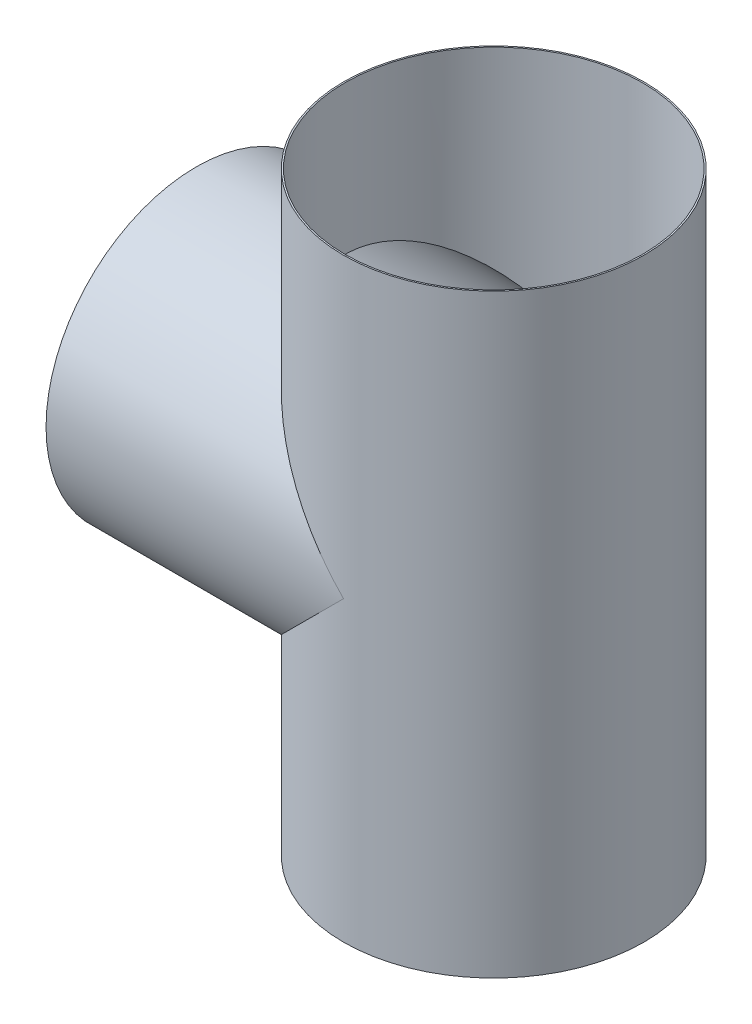
from build123d import *

# Parameters (mm, degrees)
SKETCH10_R          = 101
BOSS_EXTRUDE5_DEPTH = 200
SKETCH5_R           = 101
BOSS_EXTRUDE6_DEPTH = 400
SKETCH11_R          = 100
CUT_EXTRUDE1_DEPTH  = 400
SKETCH12_R          = 100
CUT_EXTRUDE2_DEPTH  = 200


with BuildPart() as part:
    # Sketch10 → Boss-Extrude5 (new body)
    with BuildSketch(Plane(origin=(0, 0, 0), x_dir=(0, 0, -1), z_dir=(1, 0, 0))):
        with Locations((0, 200)):
            Circle(SKETCH10_R)
    extrude(amount=BOSS_EXTRUDE5_DEPTH)

    # Sketch5 → Boss-Extrude6 (add)
    with BuildSketch(Plane(origin=(0, 0, 0), x_dir=(1, 0, 0), z_dir=(0, 1, 0))):
        with Locations((200, 0)):
            Circle(SKETCH5_R)
    extrude(amount=BOSS_EXTRUDE6_DEPTH)

    # Sketch11 → Cut-Extrude1 (cut)
    with BuildSketch(Plane(origin=(0, 400, 0), x_dir=(1, 0, 0), z_dir=(0, 1, 0))):
        with Locations((200, 0)):
            Circle(SKETCH11_R)
    extrude(amount=-CUT_EXTRUDE1_DEPTH, mode=Mode.SUBTRACT)

    # Sketch12 → Cut-Extrude2 (cut)
    with BuildSketch(Plane.ZY):
        with Locations((0, 200)):
            Circle(SKETCH12_R)
    extrude(amount=-CUT_EXTRUDE2_DEPTH, mode=Mode.SUBTRACT)


solid = part.part
